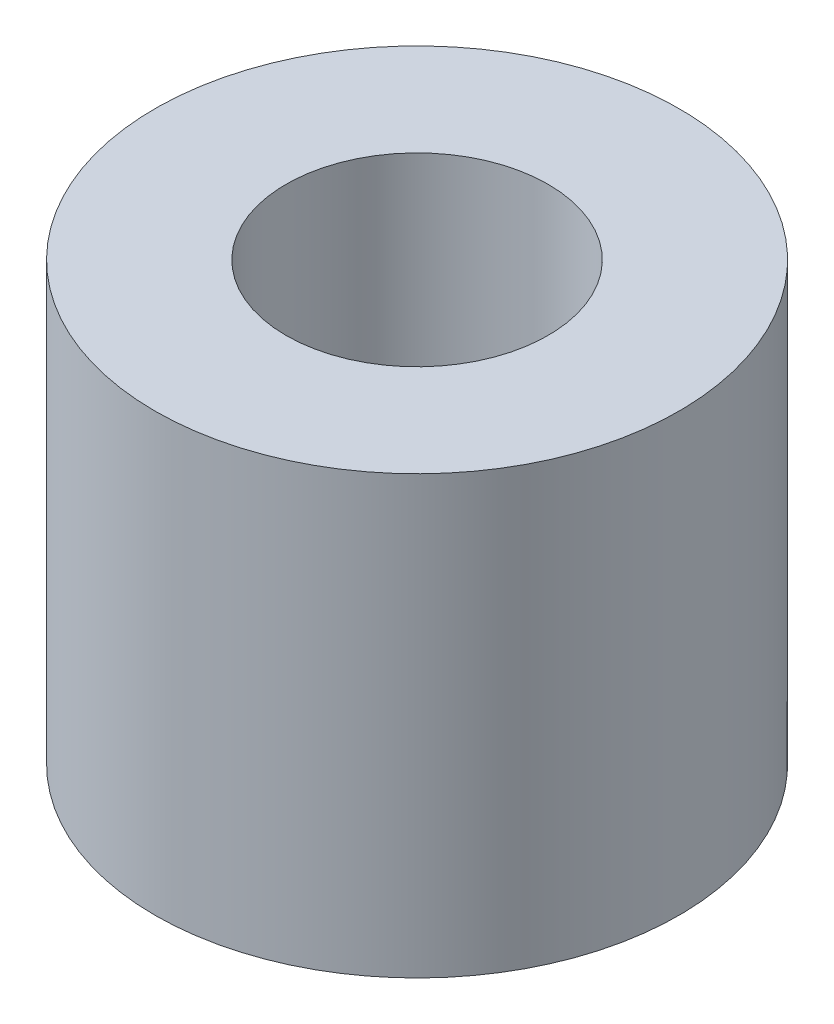
from build123d import *

# Parameters (mm, degrees)
SKETCH1_R           = 3
SKETCH1_R_2         = 1.5
BOSS_EXTRUDE1_DEPTH = 5


with BuildPart() as part:
    # Sketch1 → Boss-Extrude1 (new body)
    with BuildSketch(Plane(origin=(0, 0, 0), x_dir=(1, 0, 0), z_dir=(0, 1, 0))):
        Circle(SKETCH1_R)
        Circle(SKETCH1_R_2, mode=Mode.SUBTRACT)
    extrude(amount=BOSS_EXTRUDE1_DEPTH)


solid = part.part
